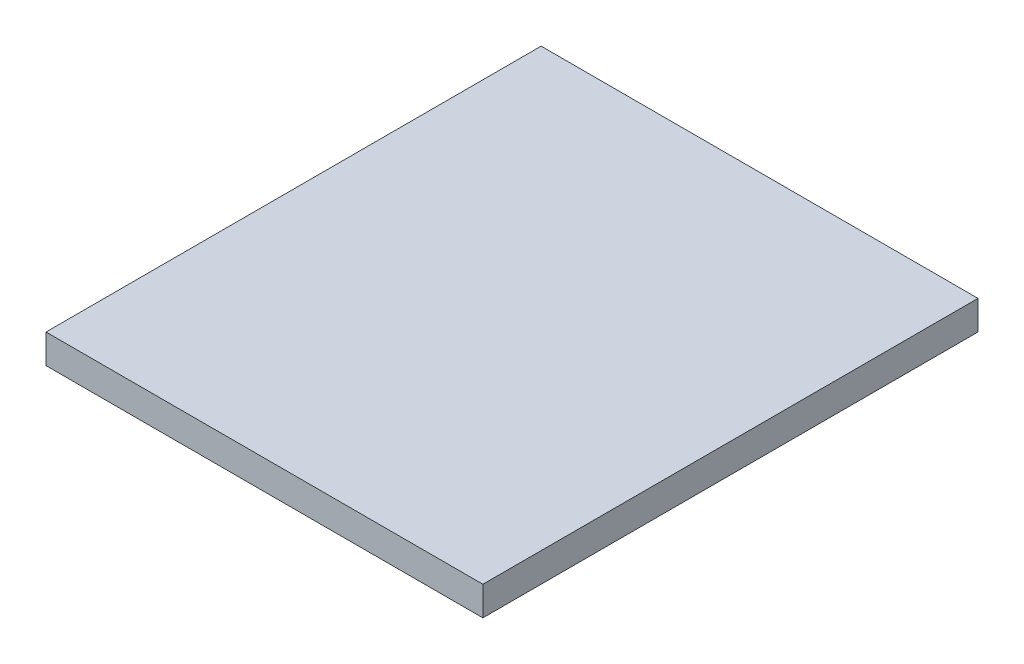
from build123d import *

# Parameters (mm, degrees)
CROQUIS1_W              = 300
CROQUIS1_H              = 20
SALIENTE_EXTRUIR1_DEPTH = 340


with BuildPart() as part:
    # Croquis1 → Saliente-Extruir1 (new body)
    with BuildSketch(Plane.XY):
        with Locations((109.354418651, 19.208924949)):
            Rectangle(CROQUIS1_W, CROQUIS1_H)
    extrude(amount=SALIENTE_EXTRUIR1_DEPTH)


solid = part.part
